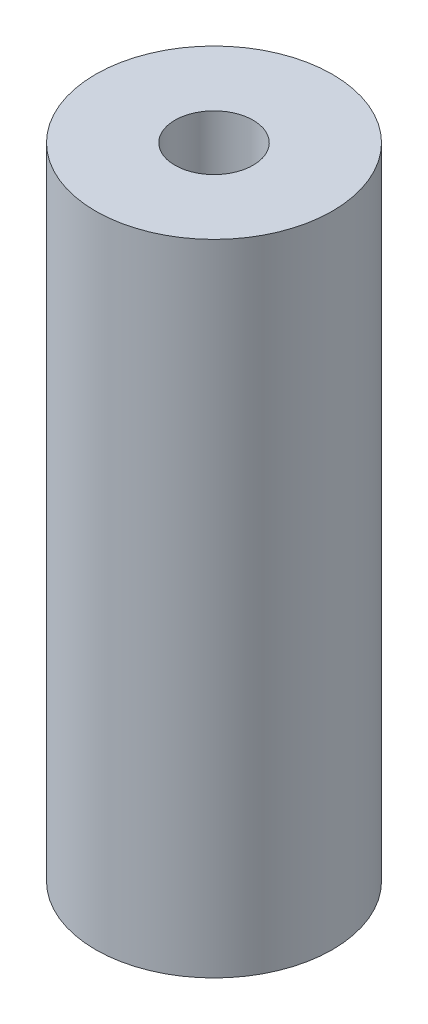
from build123d import *

# Parameters (mm, degrees)
SKETCH1_R             = 5
BOSS_EXTRUDE1_DEPTH   = 27
M4X0_7_TAPPED_HOLE1_D = 3.3


with BuildPart() as part:
    # Sketch1 → Boss-Extrude1 (new body)
    with BuildSketch(Plane(origin=(0, 0, 0), x_dir=(1, 0, 0), z_dir=(0, 1, 0))):
        Circle(SKETCH1_R)
    extrude(amount=BOSS_EXTRUDE1_DEPTH)

    # M4x0.7 Tapped Hole1 (through all)
    with Locations(Plane(origin=(0, 27, 0), x_dir=(1, 0, 0), z_dir=(0, 1, 0))):
        with Locations((0, 0)):
            Hole(M4X0_7_TAPPED_HOLE1_D / 2)


solid = part.part
